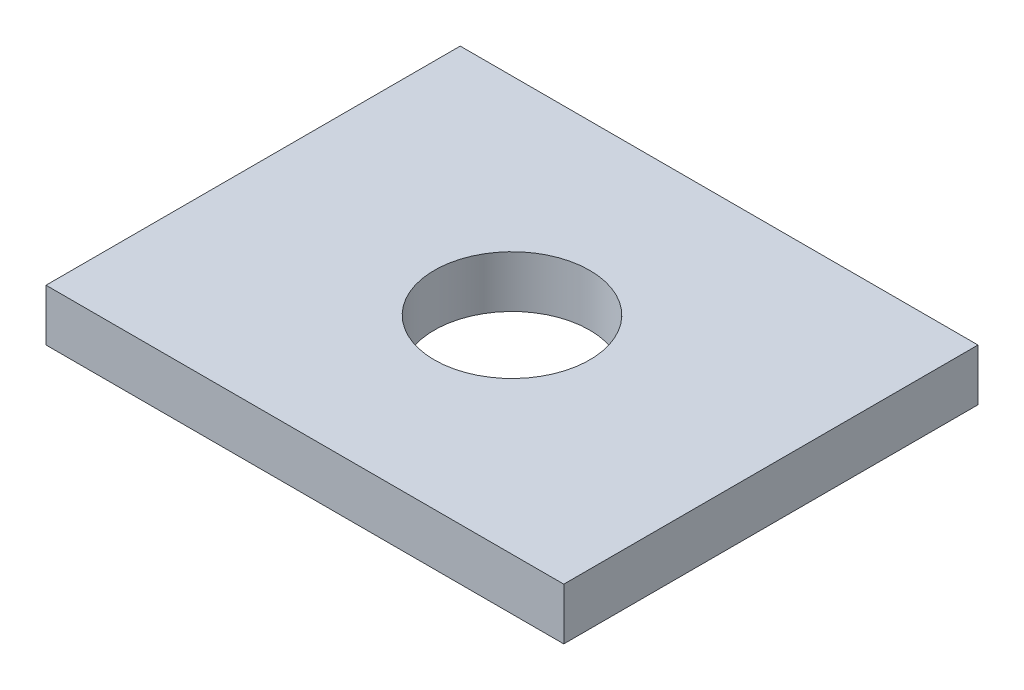
from build123d import *

# Parameters (mm, degrees)
SKETCH1_W          = 200
SKETCH1_H          = 160
BASE_DEPTH         = 20
SKETCH2_R          = 30
ACTUATOR_CUT_DEPTH = 40


with BuildPart() as part:
    # Sketch1 → base (new body)
    with BuildSketch(Plane(origin=(0, 0, 0), x_dir=(1, 0, 0), z_dir=(0, 1, 0))):
        Rectangle(SKETCH1_W, SKETCH1_H)
    extrude(amount=BASE_DEPTH)

    # Sketch2 → actuator cut (cut)
    with BuildSketch(Plane(origin=(0, 20, 0), x_dir=(1, 0, 0), z_dir=(0, 1, 0))):
        Circle(SKETCH2_R)
    extrude(amount=-ACTUATOR_CUT_DEPTH, mode=Mode.SUBTRACT)


solid = part.part
